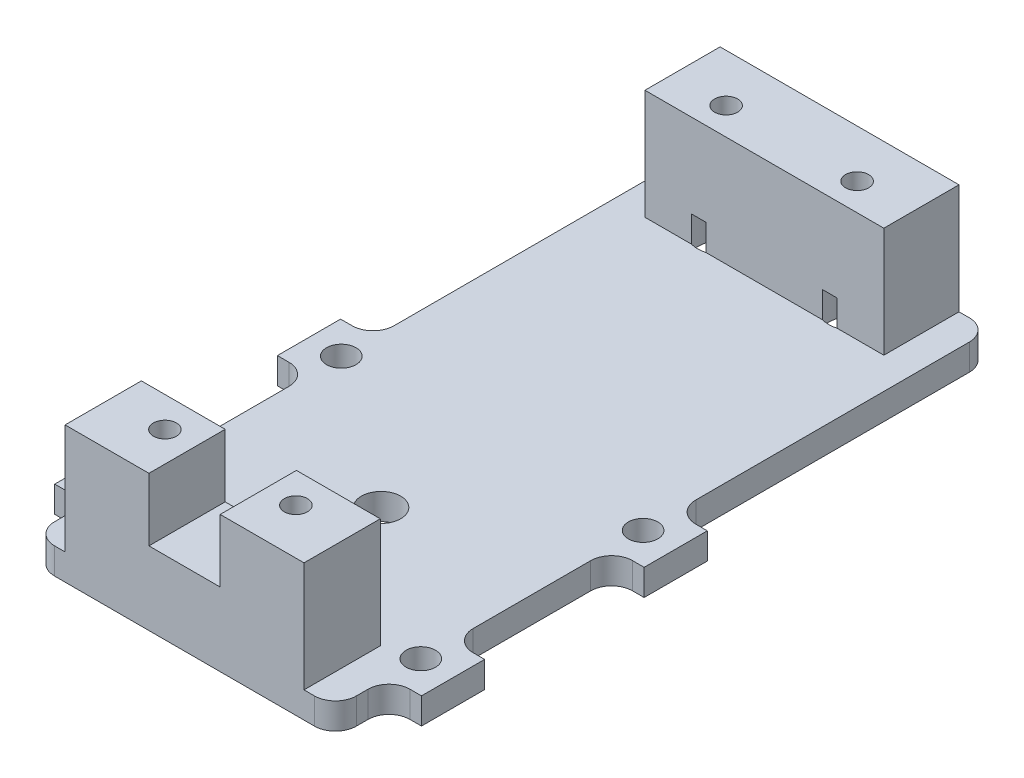
from build123d import *

# Parameters (mm, degrees)
SKETCH1_R                           = 2.381249992
BOSS_EXTRUDE1_DEPTH                 = 3.175
F_9_64_0_14063_DIAMETER_HOLE1_D     = 3.572002
F_9_64_0_14063_DIAMETER_HOLE1_DEPTH = 3.175
FILLET1_R                           = 2.54
SKETCH9_W                           = 28.956
SKETCH9_H                           = 9.242923456
SKETCH9_R                           = 1.397
SKETCH9_H_2                         = 9.1095327
BOSS_EXTRUDE3_DEPTH                 = 16.51
SKETCH10_R                          = 3.429
CUT_EXTRUDE1_DEPTH                  = 6.35
SKETCH11_W                          = 8.636
SKETCH11_H                          = 9.242923456
CUT_EXTRUDE2_DEPTH                  = 7.62


with BuildPart() as part:
    # Sketch1 → Boss-Extrude1 (new body)
    with BuildSketch(Plane(origin=(0, 0, 0), x_dir=(1, 0, 0), z_dir=(0, 1, 0))):
        Polygon((18.288, -9.6647), (22.225, -9.6647), (22.225, -17.3228), (18.288, -17.3228), (18.288, -23.8125), (-18.288, -23.8125), (-18.288, -17.3228), (-22.225, -17.3228), (-22.225, -9.6647), (-18.288, -9.6647), (-18.288, 9.6647), (-22.225, 9.6647), (-22.225, 17.3228), (-18.288, 17.3228), (-18.288, 55.5625), (18.288, 55.5625), (18.288, 17.3228), (22.225, 17.3228), (22.225, 9.6647), (18.288, 9.6647), align=None)
        with Locations((7e-09, 0.00431582)):
            Circle(SKETCH1_R, mode=Mode.SUBTRACT)
    extrude(amount=BOSS_EXTRUDE1_DEPTH)

    # 9/64 (0.14063) Diameter Hole1
    with Locations(Plane.XZ):
        with Locations((18.288000023, -13.47469999), (18.288000006, 13.466068373), (-18.288, -13.470384182), (-18.288, 13.470384182)):
            Hole(F_9_64_0_14063_DIAMETER_HOLE1_D / 2, depth=F_9_64_0_14063_DIAMETER_HOLE1_DEPTH)

    # Fillet1
    fillet1_edges = [part.edges().sort_by_distance(p)[0] for p in [
        (18.288, 1.5875, 23.8125),
        (-18.288, 1.5875, 23.8125),
        (-18.288, 1.5875, 17.3228),
        (-18.288, 1.5875, 9.6647),
        (-18.288, 1.5875, -9.6647),
        (-18.288, 1.5875, -17.3228),
        (-18.288, 1.5875, -55.5625),
        (18.288, 1.5875, -55.5625),
        (18.288, 1.5875, -17.3228),
        (18.288, 1.5875, -9.6647),
        (18.288, 1.5875, 9.6647),
        (18.288, 1.5875, 17.3228),
    ]]
    fillet(fillet1_edges, radius=FILLET1_R)

    # Sketch9 → Boss-Extrude3 (add)
    with BuildSketch(Plane(origin=(0, 0, 0), x_dir=(1, 0, 0), z_dir=(0, 1, 0))):
        with Locations((0, -19.191038272)):
            Rectangle(SKETCH9_W, SKETCH9_H)
        with Locations((-7.9375, -18.25625)):
            Circle(SKETCH9_R, mode=Mode.SUBTRACT)
        with Locations((7.9375, -18.25625)):
            Circle(SKETCH9_R, mode=Mode.SUBTRACT)
        with Locations((0.012736117, 51.00773365)):
            Rectangle(SKETCH9_W, SKETCH9_H_2)
        with Locations((-7.9375, 49.76495)):
            Circle(SKETCH9_R, mode=Mode.SUBTRACT)
        with Locations((7.9375, 49.76495)):
            Circle(SKETCH9_R, mode=Mode.SUBTRACT)
    extrude(amount=BOSS_EXTRUDE3_DEPTH)

    # Sketch10 → Cut-Extrude1 (cut)
    with BuildSketch(Plane.XZ):
        with Locations((7.9375, 18.25625)):
            Circle(SKETCH10_R)
        with Locations((-7.9375, 18.25625)):
            Circle(SKETCH10_R)
        with Locations((7.9375, -49.76495)):
            Circle(SKETCH10_R)
        with Locations((-7.9375, -49.76495)):
            Circle(SKETCH10_R)
    extrude(amount=-CUT_EXTRUDE1_DEPTH, mode=Mode.SUBTRACT)

    # Sketch11 → Cut-Extrude2 (cut)
    with BuildSketch(Plane(origin=(0, 16.51, 0), x_dir=(1, 0, 0), z_dir=(0, 1, 0))):
        with Locations((0, -19.191038272)):
            Rectangle(SKETCH11_W, SKETCH11_H)
    extrude(amount=-CUT_EXTRUDE2_DEPTH, mode=Mode.SUBTRACT)


solid = part.part
